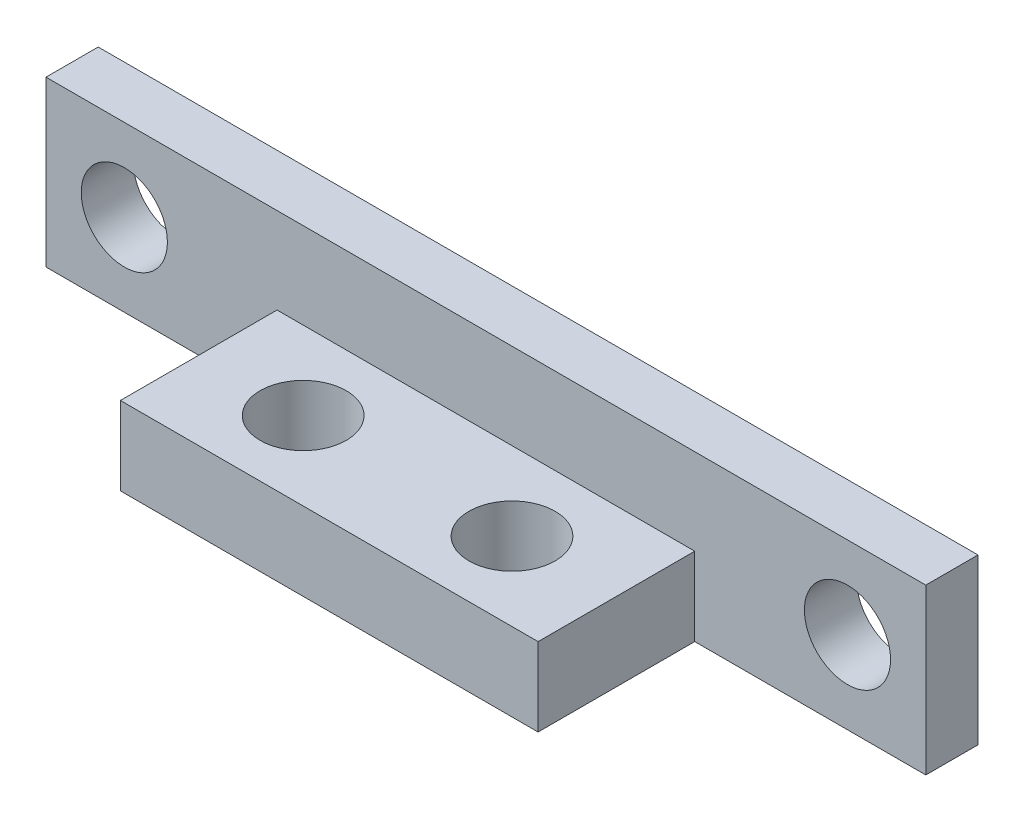
from build123d import *

# Parameters (mm, degrees)
SKETCH1_W           = 33.7
SKETCH1_H           = 6.3
SKETCH1_R           = 1.65
BOSS_EXTRUDE1_DEPTH = 2
SKETCH2_W           = 16
SKETCH2_H           = 3
BOSS_EXTRUDE2_DEPTH = 6
SKETCH3_R           = 1.65
CUT_EXTRUDE1_DEPTH  = 6


with BuildPart() as part:
    # Sketch1 → Boss-Extrude1 (new body)
    with BuildSketch(Plane.XY):
        with Locations((16.85, 3.15)):
            Rectangle(SKETCH1_W, SKETCH1_H)
        with Locations((3, 3.15)):
            Circle(SKETCH1_R, mode=Mode.SUBTRACT)
        with Locations((30.7, 3.15)):
            Circle(SKETCH1_R, mode=Mode.SUBTRACT)
    extrude(amount=BOSS_EXTRUDE1_DEPTH)

    # Sketch2 → Boss-Extrude2 (add)
    with BuildSketch(Plane.XY.offset(2)):
        with Locations((16.85, 1.5)):
            Rectangle(SKETCH2_W, SKETCH2_H)
    extrude(amount=BOSS_EXTRUDE2_DEPTH)

    # Sketch3 → Cut-Extrude1 (cut)
    with BuildSketch(Plane(origin=(0, 3, 0), x_dir=(1, 0, 0), z_dir=(0, 1, 0))):
        with Locations((12.85, -5)):
            Circle(SKETCH3_R)
        with Locations((20.85, -5)):
            Circle(SKETCH3_R)
    extrude(amount=-CUT_EXTRUDE1_DEPTH, mode=Mode.SUBTRACT)


solid = part.part
